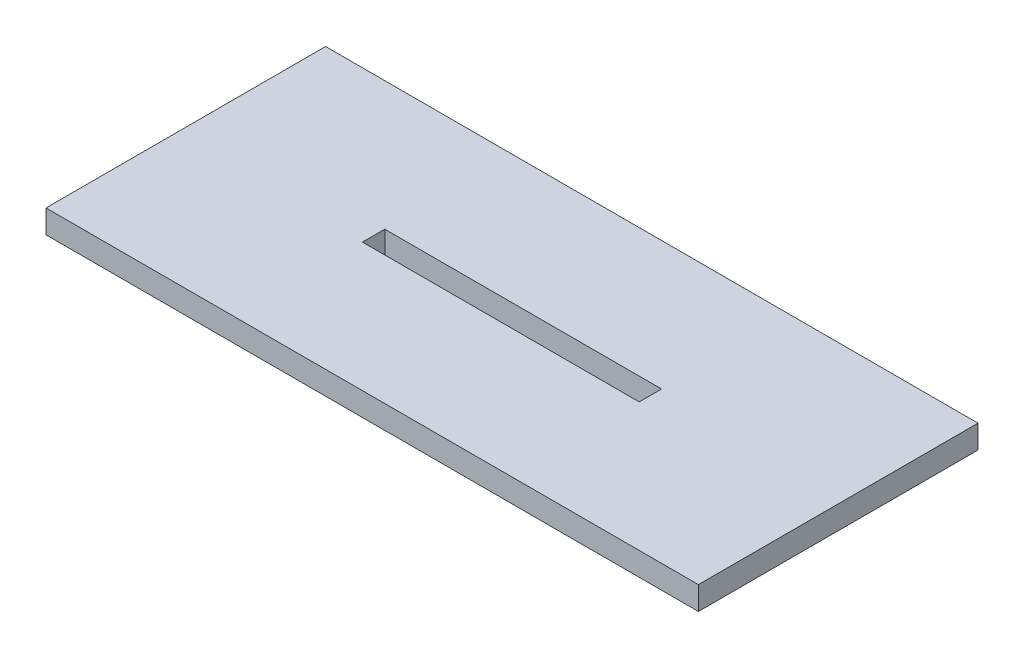
from build123d import *

# Parameters (mm, degrees)
SKETCH1_W           = 177.8
SKETCH1_H           = 76.2
BOSS_EXTRUDE1_DEPTH = 6.35
SKETCH2_W           = 75.438
SKETCH2_H           = 6.096
CUT_EXTRUDE1_DEPTH  = 7.35


with BuildPart() as part:
    # Sketch1 → Boss-Extrude1 (new body)
    with BuildSketch(Plane(origin=(0, 0, 0), x_dir=(1, 0, 0), z_dir=(0, 1, 0))):
        with Locations((88.9, 38.1)):
            Rectangle(SKETCH1_W, SKETCH1_H)
    extrude(amount=BOSS_EXTRUDE1_DEPTH)

    # Sketch2 → Cut-Extrude1 (cut, through all)
    with BuildSketch(Plane(origin=(0, 6.35, 0), x_dir=(-1, 0, 0), z_dir=(0, 1, 0))):
        with Locations((-88.9, -38.1)):
            Rectangle(SKETCH2_W, SKETCH2_H)
    extrude(amount=-CUT_EXTRUDE1_DEPTH, mode=Mode.SUBTRACT)


solid = part.part
